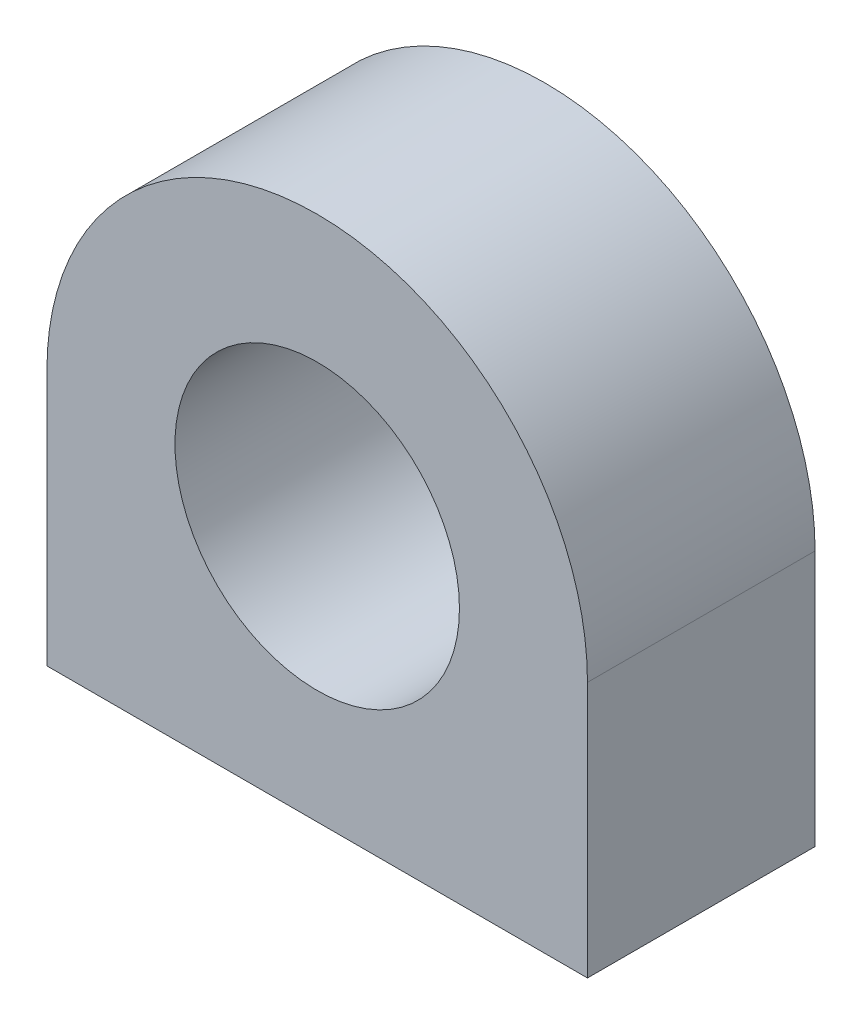
from build123d import *

# Parameters (mm, degrees)
BOSS_EXTRUDE1_DEPTH = 32
SKETCH2_R           = 20
CUT_EXTRUDE1_DEPTH  = 32


with BuildPart() as part:
    # Sketch1 → Boss-Extrude1 (new body)
    with BuildSketch(Plane.XY):
        with BuildLine():
            Line((-38, 0), (38, 0))
            Line((38, 0), (38, 36))
            ThreePointArc((38, 36), (0, 74), (-38, 36))
            Line((-38, 36), (-38, 0))
        make_face()
    extrude(amount=BOSS_EXTRUDE1_DEPTH)

    # Sketch2 → Cut-Extrude1 (cut)
    with BuildSketch(Plane.XY.offset(32)):
        with Locations((0, 36)):
            Circle(SKETCH2_R)
    extrude(amount=-CUT_EXTRUDE1_DEPTH, mode=Mode.SUBTRACT)


solid = part.part
